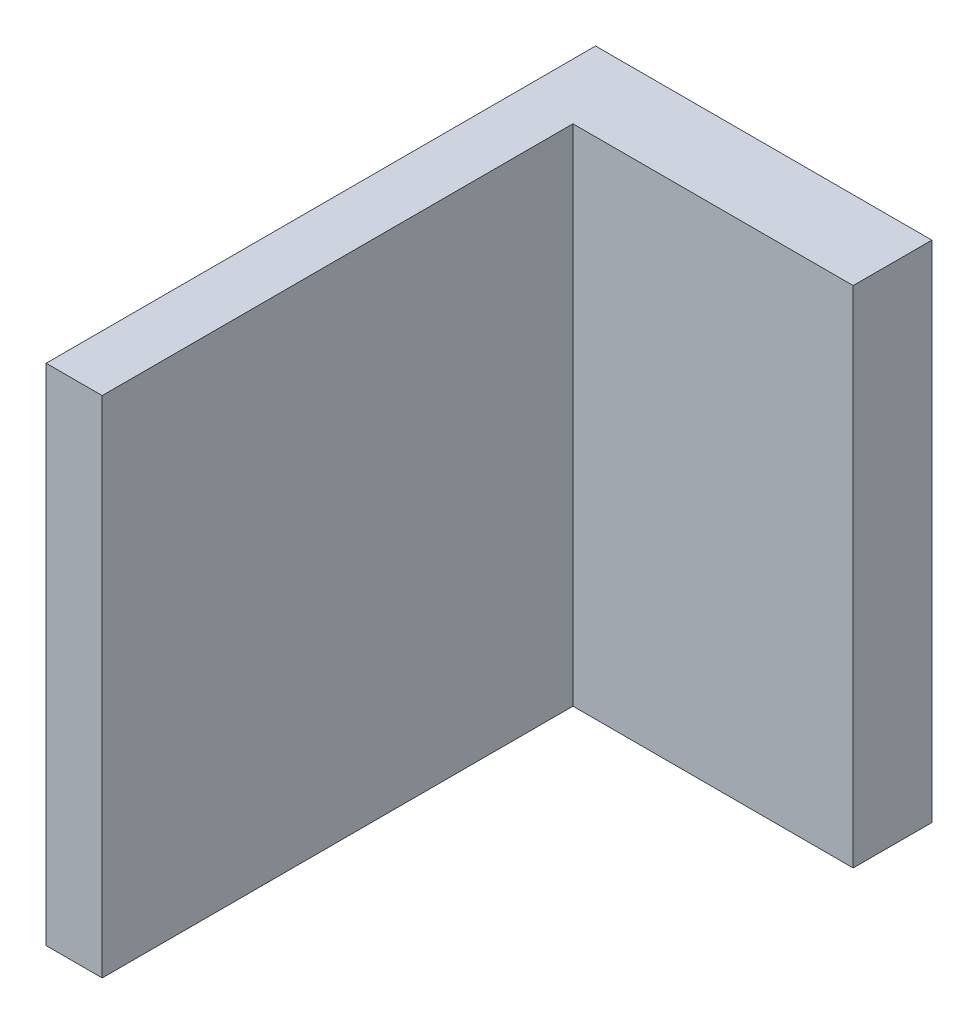
from build123d import *

# Parameters (mm, degrees)
BOSS_EXTRUDE1_DEPTH = 22.5


with BuildPart() as part:
    # Sketch1 → Boss-Extrude1 (new body)
    with BuildSketch(Plane(origin=(0, 0, 0), x_dir=(1, 0, 0), z_dir=(0, 1, 0))):
        Polygon((1.220658996, 10.253535567), (1.220658996, -10.746464433), (-1.279341004, -10.746464433), (-1.279341004, 11.263090382), (-1.279341004, 13.763090382), (13.720658996, 13.763090382), (13.720658996, 10.253535567), align=None)
    extrude(amount=BOSS_EXTRUDE1_DEPTH)


solid = part.part
